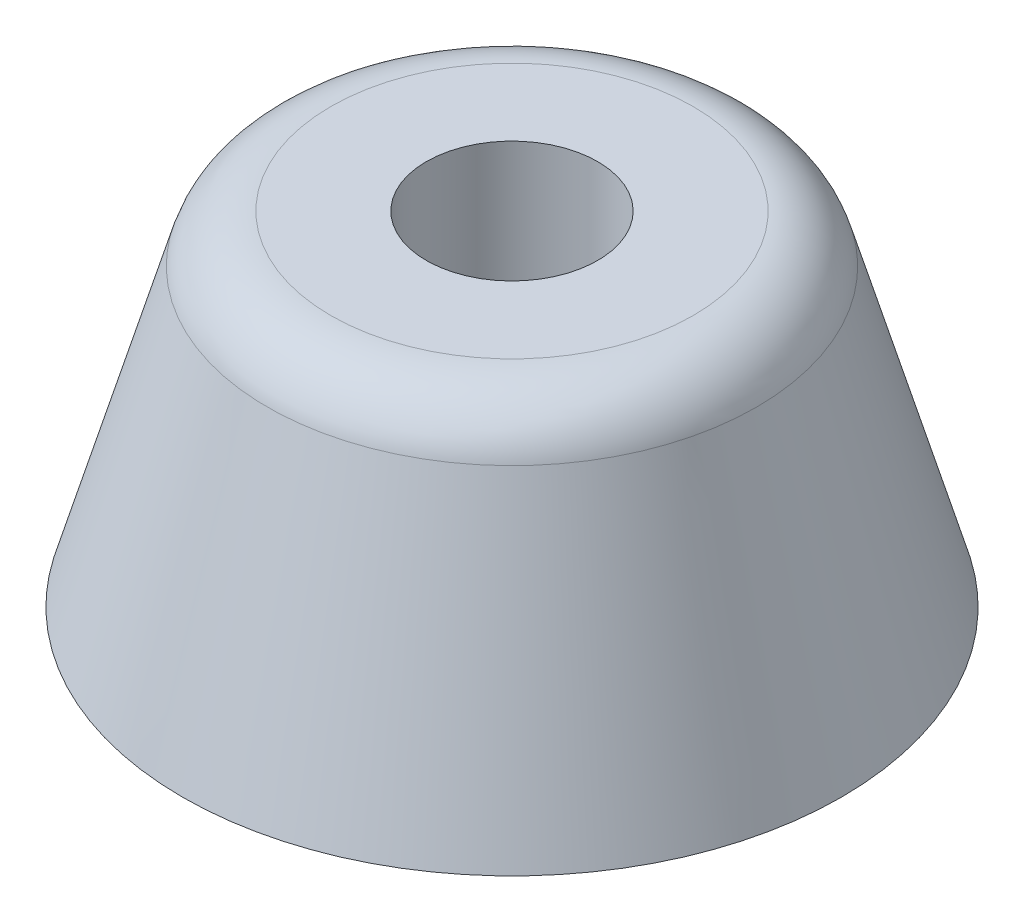
from build123d import *

# Parameters (mm, degrees)
SKETCH_1_R          = 17.5
SKETCH_2_R          = 25
SKETCH_3_R          = 6.5
CUT_EXTRUDE_1_DEPTH = 11
CUT_EXTRUDE_2_REACH = 17
SKETCH_4_R          = 4
FILLET_1_R          = 5


with BuildPart() as part:
    # 草图1 → 放样1 section 0
    with BuildSketch(Plane(origin=(0, 26, 0), x_dir=(-1, 0, 0), z_dir=(0, -1, 0))):
        Circle(SKETCH_1_R)
    # 草图2 → 放样1 section 1
    with BuildSketch(Plane(origin=(0, 0, 0), x_dir=(1, 0, 0), z_dir=(0, 1, 0))):
        Circle(SKETCH_2_R)
    loft()

    # 草图3 → 切除-拉伸1 (cut)
    with BuildSketch(Plane(origin=(0, 26, 0), x_dir=(1, 0, 0), z_dir=(0, 1, 0))):
        Circle(SKETCH_3_R)
    extrude(amount=-CUT_EXTRUDE_1_DEPTH, mode=Mode.SUBTRACT)

    # 草图4 → 切除-拉伸2 (cut, up to next)
    with BuildSketch(Plane(origin=(0, 15, 0), x_dir=(1, 0, 0), z_dir=(0, 1, 0)), mode=Mode.PRIVATE) as cut_extrude_2_sk1:
        Circle(SKETCH_4_R)
    cut_extrude_2_tool1 = extrude(cut_extrude_2_sk1.sketch, amount=-CUT_EXTRUDE_2_REACH, mode=Mode.PRIVATE) & part.part
    add(cut_extrude_2_tool1.solids().sort_by_distance((0, 15, 0))[0], mode=Mode.SUBTRACT)

    # 圆角1
    fillet_1_edges = [part.edges().sort_by_distance(p)[0] for p in [
        (17.5, 26, 0),
    ]]
    fillet(fillet_1_edges, radius=FILLET_1_R)


solid = part.part
